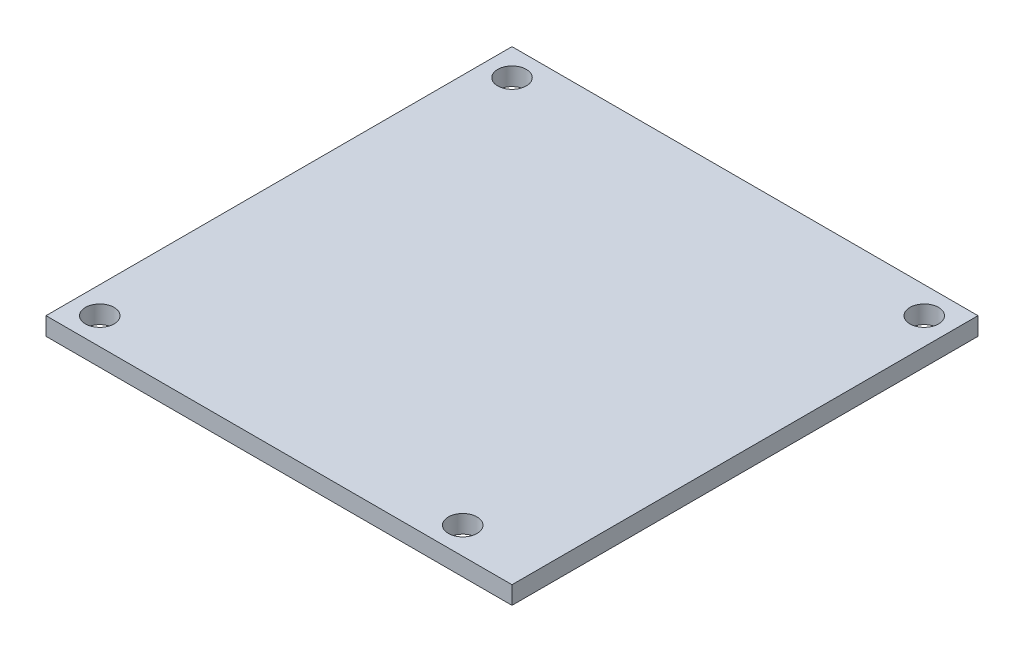
from build123d import *

# Parameters (mm, degrees)
SKETCH1_W      = 52
SKETCH1_H      = 52
EXTRUDE1_DEPTH = 2
SKETCH2_R      = 1.6
EXTRUDE2_DEPTH = 2


with BuildPart() as part:
    # Sketch1 → Extrude1 (new body)
    with BuildSketch(Plane(origin=(0, 0, 0), x_dir=(1, 0, 0), z_dir=(0, 1, 0))):
        Rectangle(SKETCH1_W, SKETCH1_H)
    extrude(amount=EXTRUDE1_DEPTH)

    # Sketch2 → Extrude2 (cut)
    with BuildSketch(Plane(origin=(0, 2, 0), x_dir=(1, 0, 0), z_dir=(0, 1, 0))):
        with Locations((23, 23)):
            Circle(SKETCH2_R)
        with Locations((-23, 23)):
            Circle(SKETCH2_R)
        with Locations((-23, -23)):
            Circle(SKETCH2_R)
        with Locations((17.5, -23)):
            Circle(SKETCH2_R)
    extrude(amount=-EXTRUDE2_DEPTH, mode=Mode.SUBTRACT)


solid = part.part
